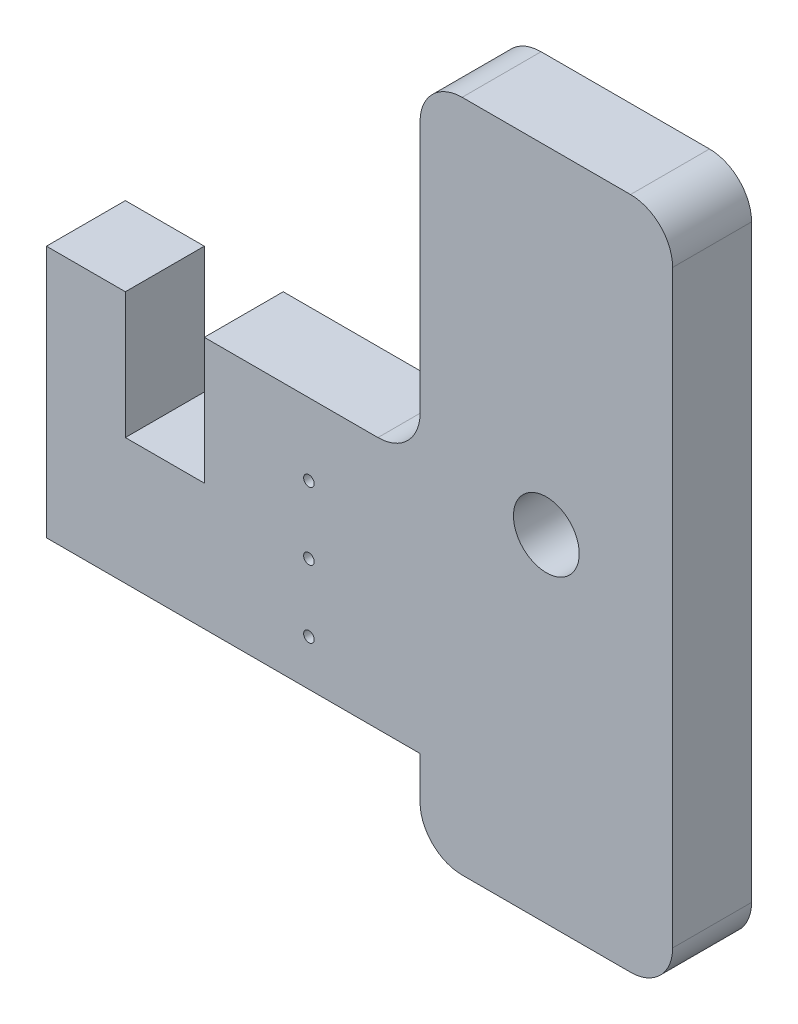
from build123d import *

# Parameters (mm, degrees)
SKETCH1_R           = 3.96875
BOSS_EXTRUDE1_DEPTH = 9.525
FILLET2_R           = 5.08
CUT_EXTRUDE1_REACH  = 11.525
SKETCH2_R           = 0.635


with BuildPart() as part:
    # Sketch1 → Boss-Extrude1 (new body)
    with BuildSketch(Plane.XY):
        Polygon((-15.24, -40.64), (15.24, -40.64), (15.24, 40.64), (-15.24, 40.64), (-15.24, 0), (-41.275, 0), (-41.275, -15.24), (-50.8, -15.24), (-50.8, 0), (-60.325, 0), (-60.325, -30.48), (-15.24, -30.48), align=None)
        Circle(SKETCH1_R, mode=Mode.SUBTRACT)
    extrude(amount=BOSS_EXTRUDE1_DEPTH)

    # Fillet2
    fillet2_edges = [part.edges().sort_by_distance(p)[0] for p in [
        (-15.24, 0, 4.7625),
        (-15.24, 40.64, 4.7625),
        (15.24, 40.64, 4.7625),
        (15.24, -40.64, 4.7625),
        (-15.24, -40.64, 4.7625),
    ]]
    fillet(fillet2_edges, radius=FILLET2_R)

    # Sketch2 → Cut-Extrude1 (cut, up to next)
    with BuildSketch(Plane.XY.offset(9.525), mode=Mode.PRIVATE) as cut_extrude1_sk1:
        with Locations((-28.6512, -8.683)):
            Circle(SKETCH2_R)
    cut_extrude1_tool1 = extrude(cut_extrude1_sk1.sketch, amount=-CUT_EXTRUDE1_REACH, mode=Mode.PRIVATE) & part.part
    add(cut_extrude1_tool1.solids().sort_by_distance((-28.6512, -8.683, 9.525))[0], mode=Mode.SUBTRACT)
    # Sketch2 → Cut-Extrude1 (cut, up to next)
    with BuildSketch(Plane.XY.offset(9.525), mode=Mode.PRIVATE) as cut_extrude1_sk2:
        with Locations((-28.6512, -16.825545611)):
            Circle(SKETCH2_R)
    cut_extrude1_tool2 = extrude(cut_extrude1_sk2.sketch, amount=-CUT_EXTRUDE1_REACH, mode=Mode.PRIVATE) & part.part
    add(cut_extrude1_tool2.solids().sort_by_distance((-28.6512, -16.825546, 9.525))[0], mode=Mode.SUBTRACT)
    # Sketch2 → Cut-Extrude1 (cut, up to next)
    with BuildSketch(Plane.XY.offset(9.525), mode=Mode.PRIVATE) as cut_extrude1_sk3:
        with Locations((-28.6512, -24.968091222)):
            Circle(SKETCH2_R)
    cut_extrude1_tool3 = extrude(cut_extrude1_sk3.sketch, amount=-CUT_EXTRUDE1_REACH, mode=Mode.PRIVATE) & part.part
    add(cut_extrude1_tool3.solids().sort_by_distance((-28.6512, -24.968091, 9.525))[0], mode=Mode.SUBTRACT)


solid = part.part
